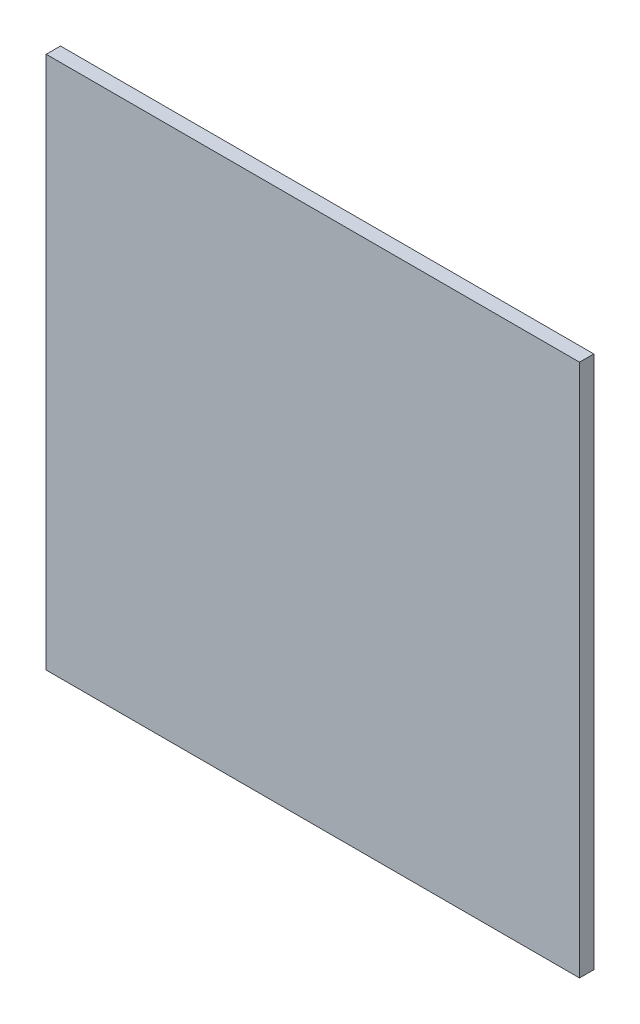
from build123d import *

# Parameters (mm, degrees)
SKETCH1_W           = 56
SKETCH1_H           = 56
BOSS_EXTRUDE1_DEPTH = 1.5


with BuildPart() as part:
    # Sketch1 → Boss-Extrude1 (new body)
    with BuildSketch(Plane.XY):
        Rectangle(SKETCH1_W, SKETCH1_H)
    extrude(amount=BOSS_EXTRUDE1_DEPTH)


solid = part.part
